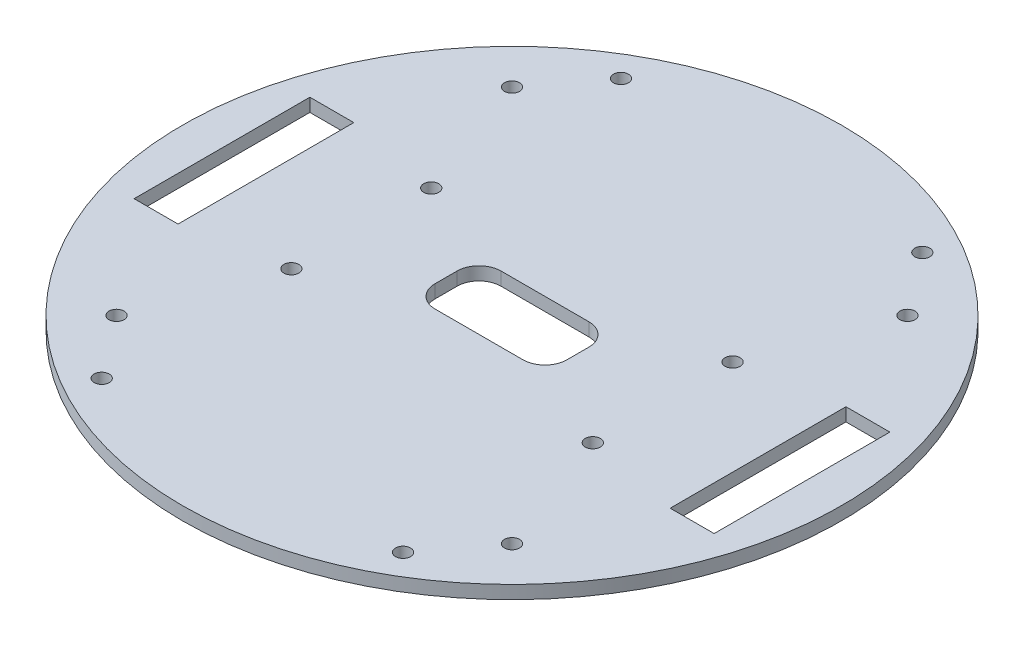
from build123d import *

# Parameters (mm, degrees)
SKETCH1_R           = 75
BOSS_EXTRUDE1_DEPTH = 3
SKETCH2_W           = 10
SKETCH2_H           = 40
CUT_EXTRUDE1_DEPTH  = 6.35
SKETCH8_R           = 1.7145
CUT_EXTRUDE7_DEPTH  = 4
SKETCH9_W           = 30
SKETCH9_H           = 15
CUT_EXTRUDE8_DEPTH  = 4
FILLET1_R           = 5
SKETCH10_R          = 1.7145
CUT_EXTRUDE9_DEPTH  = 10


with BuildPart() as part:
    # Sketch1 → Boss-Extrude1 (new body)
    with BuildSketch(Plane(origin=(0, 0, 0), x_dir=(1, 0, 0), z_dir=(0, 1, 0))):
        Circle(SKETCH1_R)
    extrude(amount=BOSS_EXTRUDE1_DEPTH)

    # Sketch2 → Cut-Extrude1 (cut)
    with BuildSketch(Plane(origin=(0, 3, 0), x_dir=(1, 0, 0), z_dir=(0, 1, 0))):
        with Locations((-61, 0)):
            Rectangle(SKETCH2_W, SKETCH2_H)
        with Locations((61, 0)):
            Rectangle(SKETCH2_W, SKETCH2_H)
    extrude(amount=-CUT_EXTRUDE1_DEPTH, mode=Mode.SUBTRACT)

    # Sketch8 → Cut-Extrude7 (cut, through all)
    with BuildSketch(Plane(origin=(0, 3, 0), x_dir=(1, 0, 0), z_dir=(0, 1, 0))):
        with Locations((-45, 45)):
            Circle(SKETCH8_R)
        with Locations((45, 45)):
            Circle(SKETCH8_R)
        with Locations((45, -45)):
            Circle(SKETCH8_R)
        with Locations((-45, -45)):
            Circle(SKETCH8_R)
    extrude(amount=-CUT_EXTRUDE7_DEPTH, mode=Mode.SUBTRACT)

    # Sketch9 → Cut-Extrude8 (cut, through all)
    with BuildSketch(Plane(origin=(0, 3, 0), x_dir=(1, 0, 0), z_dir=(0, 1, 0))):
        Rectangle(SKETCH9_W, SKETCH9_H)
    extrude(amount=-CUT_EXTRUDE8_DEPTH, mode=Mode.SUBTRACT)

    # Fillet1
    fillet1_edges = [part.edges().sort_by_distance(p)[0] for p in [
        (15, 1.5, -7.5),
        (15, 1.5, 7.5),
        (-15, 1.5, 7.5),
        (-15, 1.5, -7.5),
    ]]
    fillet(fillet1_edges, radius=FILLET1_R)

    # Sketch10 → Cut-Extrude9 (cut)
    with BuildSketch(Plane(origin=(0, 3, 0), x_dir=(1, 0, 0), z_dir=(0, 1, 0))):
        with Locations((34.29, 59.09)):
            Circle(SKETCH10_R)
        with Locations((34.29, 15.91)):
            Circle(SKETCH10_R)
        with Locations((-34.29, 15.91)):
            Circle(SKETCH10_R)
        with Locations((-34.29, 59.09)):
            Circle(SKETCH10_R)
        with Locations((-34.29, -15.91)):
            Circle(SKETCH10_R)
        with Locations((-34.29, -59.09)):
            Circle(SKETCH10_R)
        with Locations((34.29, -59.09)):
            Circle(SKETCH10_R)
        with Locations((34.29, -15.91)):
            Circle(SKETCH10_R)
    extrude(amount=-CUT_EXTRUDE9_DEPTH, mode=Mode.SUBTRACT)


solid = part.part
